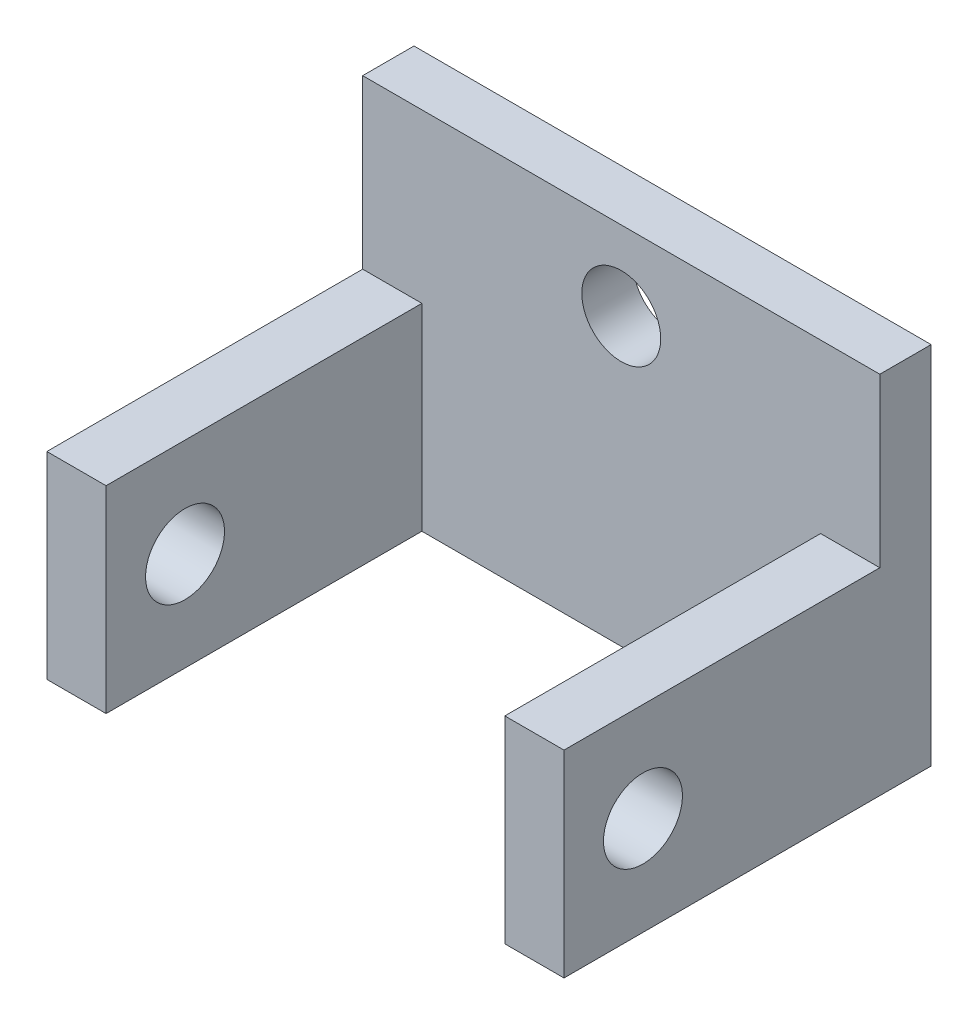
from build123d import *

# Parameters (mm, degrees)
SKETCH_1_W          = 13.1
SKETCH_1_H          = 9.245579741
SKETCH_1_R          = 1
EXTRUDE_1_DEPTH     = 1.3
SKETCH_2_W          = 1.5
SKETCH_2_H          = 5
EXTRUDE_2_DEPTH     = 8
SKETCH_4_R          = 1
CUT_EXTRUDE_1_DEPTH = 15


with BuildPart() as part:
    # 草图1 → 凸台-拉伸1 (new body)
    with BuildSketch(Plane.XY):
        with Locations((6.55, 4.622789871)):
            Rectangle(SKETCH_1_W, SKETCH_1_H)
        with Locations((6.55, 7.245579741)):
            Circle(SKETCH_1_R, mode=Mode.SUBTRACT)
    extrude(amount=EXTRUDE_1_DEPTH)

    # 草图2 → 凸台-拉伸2 (add)
    with BuildSketch(Plane.XY.offset(1.3)):
        with Locations((0.75, 2.5)):
            Rectangle(SKETCH_2_W, SKETCH_2_H)
        with Locations((12.35, 2.5)):
            Rectangle(SKETCH_2_W, SKETCH_2_H)
    extrude(amount=EXTRUDE_2_DEPTH)

    # 草图4 → 切除-拉伸1 (cut)
    with BuildSketch(Plane.ZY):
        with Locations((7.3, 2.5)):
            Circle(SKETCH_4_R)
    extrude(amount=-CUT_EXTRUDE_1_DEPTH, mode=Mode.SUBTRACT)


solid = part.part
